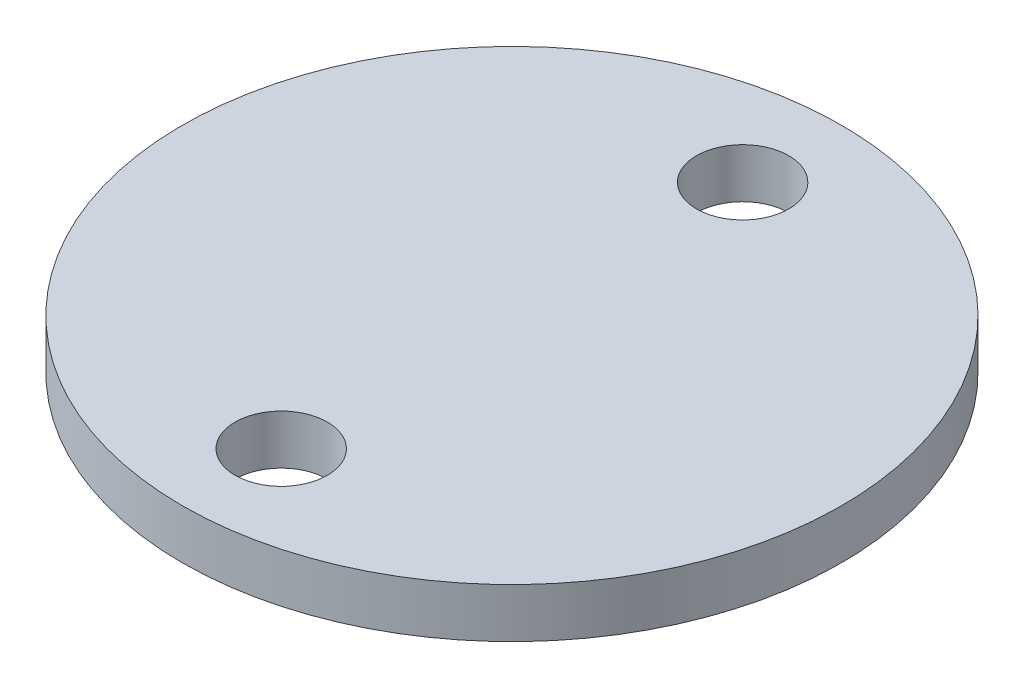
from build123d import *

# Parameters (mm, degrees)
SKETCH1_R           = 10
BOSS_EXTRUDE1_DEPTH = 1.5
SKETCH2_R           = 1.4
CUT_EXTRUDE1_DEPTH  = 2.5
SKETCH3_R           = 3.5
BOSS_EXTRUDE2_DEPTH = 3.5
FILLET1_R           = 0.5


with BuildPart() as part:
    # Sketch1 → Boss-Extrude1 (new body)
    with BuildSketch(Plane(origin=(0, 0, 0), x_dir=(1, 0, 0), z_dir=(0, 1, 0))):
        Circle(SKETCH1_R)
    extrude(amount=-BOSS_EXTRUDE1_DEPTH)

    # Sketch2 → Cut-Extrude1 (cut, through all)
    with BuildSketch(Plane(origin=(0, 0, 0), x_dir=(1, 0, 0), z_dir=(0, 1, 0))):
        with Locations((0, 7)):
            Circle(SKETCH2_R)
        with Locations((0, -7)):
            Circle(SKETCH2_R)
    extrude(amount=-CUT_EXTRUDE1_DEPTH, mode=Mode.SUBTRACT)

    # Sketch3 → Boss-Extrude2 (add)
    with BuildSketch(Plane.XZ.offset(1.5)):
        Circle(SKETCH3_R)
        with BuildLine():
            Line((1.985734783, 1.647196822), (2.166931392, -1.400288664))
            ThreePointArc((2.166931392, -1.400288664), (-2.575451618, -0.15313054), (1.985734783, 1.647196822))
        make_face(mode=Mode.SUBTRACT)
    extrude(amount=BOSS_EXTRUDE2_DEPTH)

    # Fillet1
    fillet1_edges = [part.edges().sort_by_distance(p)[0] for p in [
        (-2.575451618, -5, -0.15313054),
        (2.076333088, -5, 0.123454079),
    ]]
    fillet(fillet1_edges, radius=FILLET1_R)


solid = part.part
